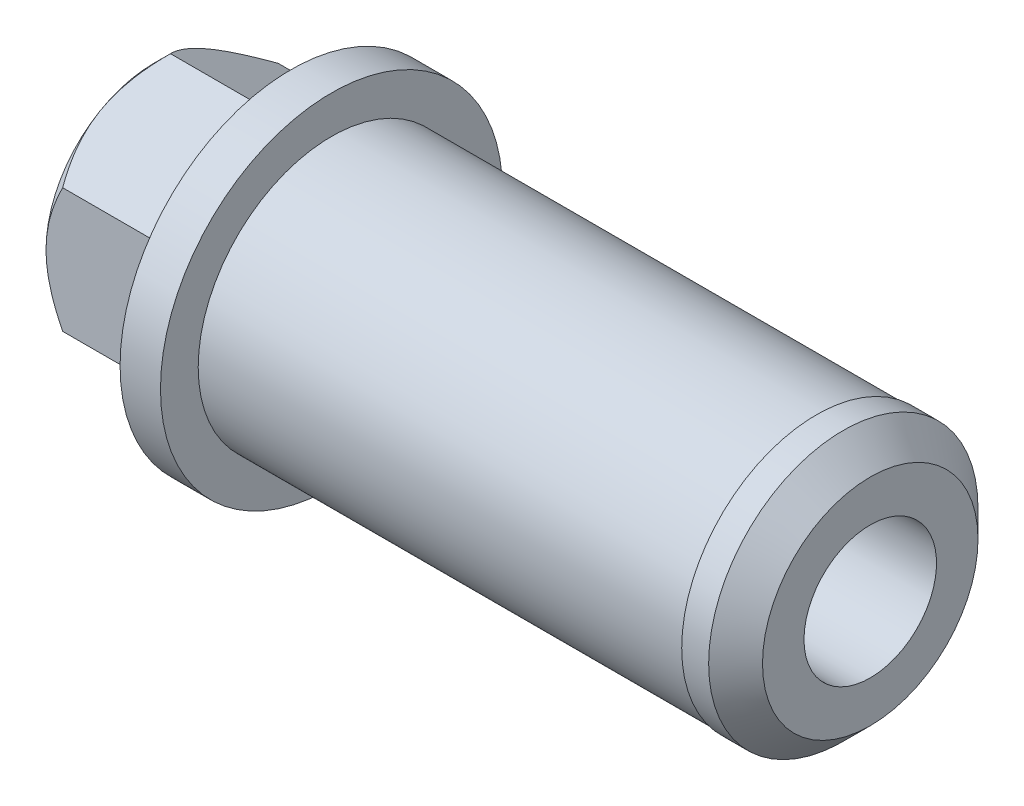
from build123d import *

# Parameters (mm, degrees)
SFAZOWANIE1_SIZE            = 1
SZKIC2_R                    = 2.46
DODANIE_WYCI_GNI_CIE1_DEPTH = 5.1
SFAZOWANIE2_SIZE            = 0.5


with BuildPart() as part:
    # Szkic1 → Obrót1 (revolve)
    with BuildSketch(Plane(origin=(0, 0, 0), x_dir=(1, 0, 0), z_dir=(0, 1, 0))):
        Polygon((0, 2.46), (0, 6.35), (1.5, 6.35), (1.5, 4.95), (19.5, 4.95), (19.5, 5), (21.5, 5), (21.5, 2.46), align=None)
    revolve(axis=Axis((0, 0, 0), (1, 0, 0)))

    # Sfazowanie1
    sfazowanie1_edges = [part.edges().sort_by_distance(p)[0] for p in [
        (21.5, 0, 5),
    ]]
    chamfer(sfazowanie1_edges, length=SFAZOWANIE1_SIZE)

    # Szkic2 → Dodanie-wyciągnięcie1 (add)
    with BuildSketch(Plane.ZY):
        Polygon((4, -2.309401077), (4, 2.309401077), (0, 4.618802154), (-4, 2.309401077), (-4, -2.309401077), (0, -4.618802154), align=None)
        Circle(SZKIC2_R, mode=Mode.SUBTRACT)
    extrude(amount=DODANIE_WYCI_GNI_CIE1_DEPTH)

    # Szkic3 → Wycięcie-obrót1 (revolve, cut)
    with BuildSketch(Plane.XY):
        Polygon((-5.1, 4.618802154), (-4.481197846, 4.618802154), (-5.1, 4), align=None)
    revolve(axis=Axis((-4.836570642, 0, 0), (-1, 0, 0)), mode=Mode.SUBTRACT)

    # Sfazowanie2
    sfazowanie2_edges = [part.edges().sort_by_distance(p)[0] for p in [
        (-5.1, 0, -2.46),
    ]]
    chamfer(sfazowanie2_edges, length=SFAZOWANIE2_SIZE)


solid = part.part
